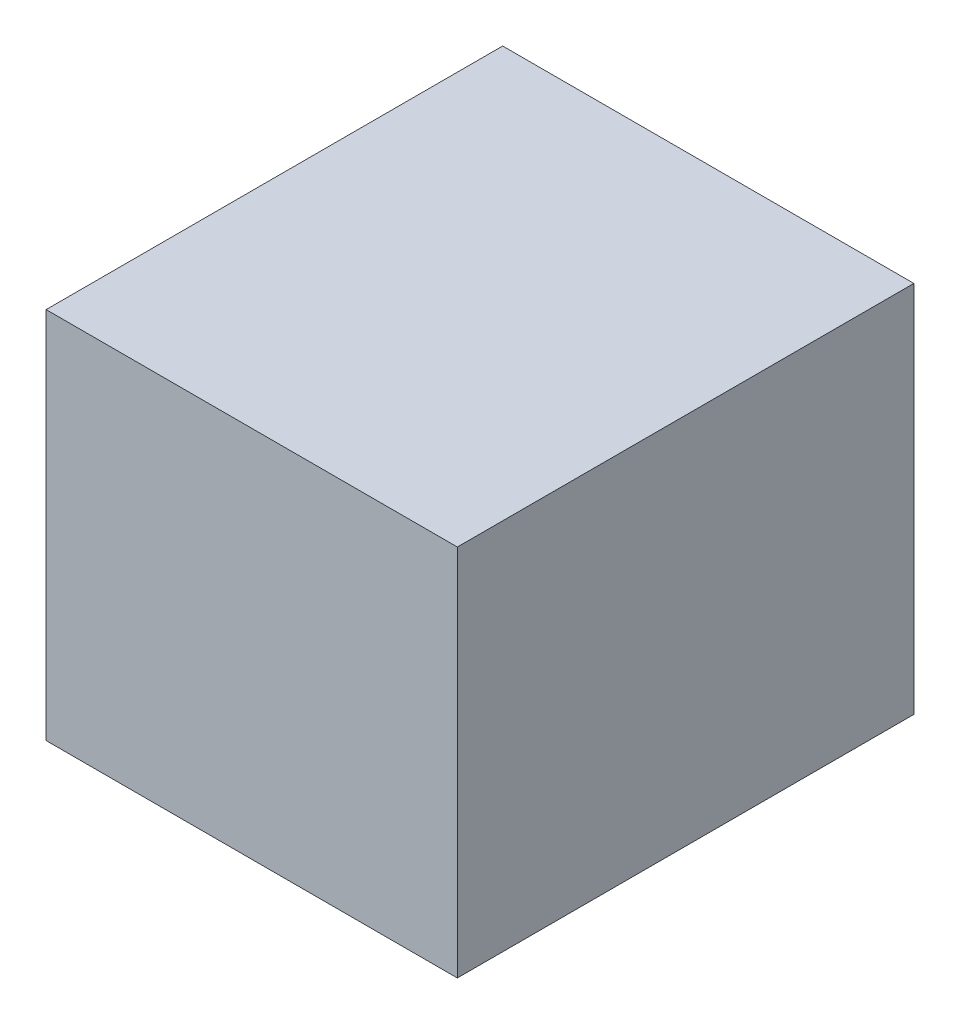
from build123d import *

# Parameters (mm, degrees)
Y_KSEKLIK_EKSTR_ZYON1_DEPTH      = 54.991
Y_KSEKLIK_EKSTR_ZYON1_DEPTH_BACK = 54.991
IZIM1_W                          = 99.06
IZIM1_H                          = 89.916


with BuildPart() as part:
    # Çizim1 → Yükseklik-Ekstrüzyon1 (new, two sides: drawn at the far end of the back side and taken through both)
    with BuildSketch(Plane.XY.offset(-Y_KSEKLIK_EKSTR_ZYON1_DEPTH_BACK)):
        Rectangle(IZIM1_W, IZIM1_H)
    extrude(amount=Y_KSEKLIK_EKSTR_ZYON1_DEPTH + Y_KSEKLIK_EKSTR_ZYON1_DEPTH_BACK)


solid = part.part
